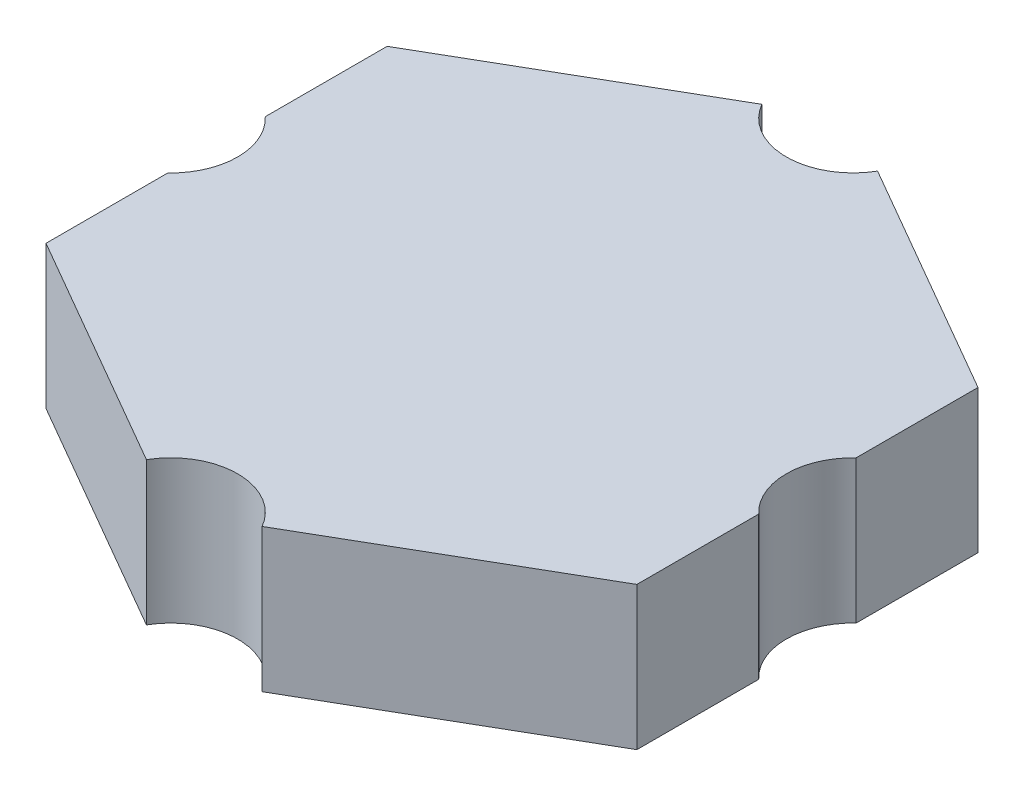
from build123d import *

# Parameters (mm, degrees)
BOSS_EXTRUDE1_DEPTH = 3
SKETCH3_R           = 1.4
CUT_EXTRUDE1_DEPTH  = 9.45


with BuildPart() as part:
    # Sketch2 → Boss-Extrude1 (new body)
    with BuildSketch(Plane(origin=(0, 0, 0), x_dir=(1, 0, 0), z_dir=(0, 1, 0))):
        Polygon((0, 7.15), (-6.192081637, 3.575), (-6.192081637, -3.575), (0, -7.15), (6.192081637, -3.575), (6.192081637, 3.575), align=None)
    extrude(amount=BOSS_EXTRUDE1_DEPTH)

    # Sketch3 → Cut-Extrude1 (cut)
    with BuildSketch(Plane(origin=(0, 3, 0), x_dir=(1, 0, 0), z_dir=(0, 1, 0))):
        with Locations((0, 7.15)):
            Circle(SKETCH3_R)
        with Locations((7.15, 0)):
            Circle(SKETCH3_R)
        with Locations((0, -7.15)):
            Circle(SKETCH3_R)
        with Locations((-7.15, 0)):
            Circle(SKETCH3_R)
    extrude(amount=-CUT_EXTRUDE1_DEPTH, mode=Mode.SUBTRACT)


solid = part.part
